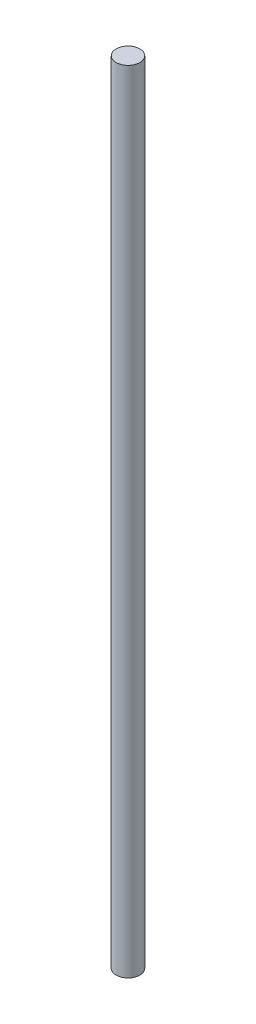
from build123d import *

# Parameters (mm, degrees)
SKETCH1_R           = 1.5
BOSS_EXTRUDE1_DEPTH = 100


with BuildPart() as part:
    # Sketch1 → Boss-Extrude1 (new body)
    with BuildSketch(Plane(origin=(0, 0, 0), x_dir=(1, 0, 0), z_dir=(0, 1, 0))):
        Circle(SKETCH1_R)
    extrude(amount=BOSS_EXTRUDE1_DEPTH)


solid = part.part
